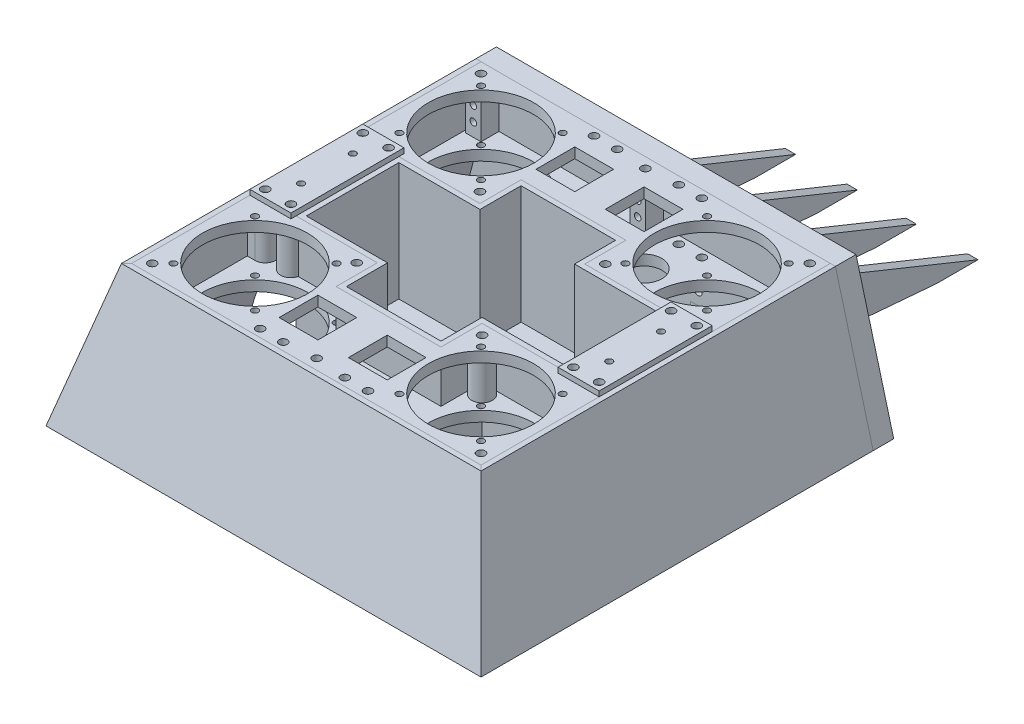
from build123d import *

# Parameters (mm, degrees)
SKETCH3_W               = 107.95
SKETCH3_H               = 76.2
SKETCH3_R               = 32.5
BOSS_EXTRUDE1_DEPTH     = 6.35
SKETCH12_W              = 25.4
SKETCH12_H              = 6.35
BOSS_EXTRUDE8_DEPTH     = 6.35
SKETCH5_R               = 10.9728
CUT_EXTRUDE1_DEPTH      = 156.930970304
SKETCH47_W              = 24
SKETCH47_H              = 24
CUT_EXTRUDE19_DEPTH     = 6.35
SKETCH22_R              = 2.0193
CUT_EXTRUDE7_DEPTH      = 158.346798506
SKETCH33_R              = 2.5527
CUT_EXTRUDE10_DEPTH     = 158.346798506
SKETCH18_R              = 2.5527
CUT_EXTRUDE5_DEPTH      = 158.346798506
CUT_EXTRUDE5_DEPTH_BACK = 158.346798506
SKETCH19_W              = 64.782960534
SKETCH19_H              = 25.4
CUT_EXTRUDE6_DEPTH      = 158.346798506
CUT_EXTRUDE6_DEPTH_BACK = 158.346798506
CIRPATTERN2_COUNT       = 2
SKETCH13_W              = 25.4
SKETCH13_H              = 69.85
BOSS_EXTRUDE9_DEPTH     = 3.175
SKETCH14_R              = 2
CUT_EXTRUDE2_DEPTH      = 3.175
SKETCH16_R              = 2.5527
CUT_EXTRUDE4_DEPTH      = 180.941566904
CUT_EXTRUDE4_DEPTH_BACK = 180.941566904
BOSS_EXTRUDE10_DEPTH    = 73.025
BOSS_EXTRUDE11_DEPTH    = 9.525
SKETCH26_R              = 6.35
BOSS_EXTRUDE12_DEPTH    = 25.4
SKETCH27_R              = 4.7625
CUT_EXTRUDE8_DEPTH      = 171.6248663
BOSS_EXTRUDE5_DEPTH     = 12.7
BOSS_EXTRUDE13_DEPTH    = 25.4
SKETCH29_R              = 4.7625
CUT_EXTRUDE9_DEPTH      = 210.078448268
SKETCH34_W              = 9.525
SKETCH34_H              = 11.1125
BOSS_EXTRUDE14_DEPTH    = 25.4
SKETCH36_R              = 2.0193
CUT_EXTRUDE11_DEPTH     = 207.517029638
LPATTERN1_COUNT         = 3
LPATTERN1_PITCH         = 101.6
SKETCH37_R              = 2.5527
CUT_EXTRUDE12_DEPTH     = 304.667377102
SKETCH38_R              = 2.0193
CUT_EXTRUDE13_DEPTH     = 294.080195203
SKETCH39_R              = 4.7625
BOSS_EXTRUDE15_DEPTH    = 4.7625
LPATTERN2_COUNT         = 2
LPATTERN2_PITCH         = 38.1
SKETCH40_R              = 2.5527
SKETCH40_W              = 9.525
SKETCH40_H              = 9.525
CUT_EXTRUDE14_DEPTH     = 294.080195203
SKETCH41_R              = 2.0193
CUT_EXTRUDE15_DEPTH     = 304.667377102
SKETCH43_R              = 18
CUT_EXTRUDE17_DEPTH     = 44.45
CUT_EXTRUDE16_START     = -82.55
CUT_EXTRUDE16_DEPTH     = 137.363629721
SKETCH44_R              = 14
CUT_EXTRUDE18_DEPTH     = 38.1
BOSS_EXTRUDE16_START    = 12.7
SKETCH45_R              = 4.7625
BOSS_EXTRUDE16_DEPTH    = 163.5125
SKETCH46_R              = 5.3975
BOSS_EXTRUDE17_DEPTH    = 6.35
LPATTERN3_COUNT         = 2
LPATTERN3_PITCH         = 38.1


with BuildPart() as part:
    # Sketch3 → Boss-Extrude1 (new body)
    with BuildSketch(Plane(origin=(0, 53.975, 0), x_dir=(1, 0, 0), z_dir=(0, 1, 0))):
        with Locations((-53.975, 69.85)):
            Rectangle(SKETCH3_W, SKETCH3_H)
        with Locations(Location((-69.85, 69.85, 0), (0, 0, 270))):
            Circle(SKETCH3_R, mode=Mode.SUBTRACT)
    extrude(amount=BOSS_EXTRUDE1_DEPTH)

    # Sketch12 → Boss-Extrude8 (add)
    with BuildSketch(Plane(origin=(0, 60.325, 0), x_dir=(1, 0, 0), z_dir=(0, 1, 0))):
        with Locations((-95.25, 28.575)):
            Rectangle(SKETCH12_W, SKETCH12_H)
    extrude(amount=-BOSS_EXTRUDE8_DEPTH)


with BuildPart() as body_2:
    # Mirror1: mirrored copy
    add(part.part.mirror(Plane.ZX.offset(73.025)))

    # Mirror2 2: body 2 across plane


with BuildPart() as part_1:
    add(part.part)

    # Mirror2: part across plane
    add(part.part.mirror(Plane(origin=(0, 0, 0), x_dir=(0, 0, 1), z_dir=(1, 0, 0))))

    # Sketch5 → Cut-Extrude1 (cut, through all)
    with BuildSketch(Plane(origin=(0, 60.325, 0), x_dir=(1, 0, 0), z_dir=(0, 1, 0))):
        with Locations(Location((-21.415333079, 79.375, 0), (0, 0, 270))):
            Circle(SKETCH5_R)
    cut_extrude1 = extrude(amount=-CUT_EXTRUDE1_DEPTH, mode=Mode.SUBTRACT)


with BuildPart() as body_2_1:
    add(body_2.part)
    add(body_2.part.mirror(Plane(origin=(0, 0, 0), x_dir=(0, 0, 1), z_dir=(1, 0, 0))))

    # Sketch47 → Cut-Extrude19 (cut)
    with BuildSketch(Plane(origin=(0, 92.075, 0), x_dir=(1, 0, 0), z_dir=(0, 1, 0))):
        with Locations((-21.415333079, 79.375)):
            Rectangle(SKETCH47_W, SKETCH47_H)
    cut_extrude19 = extrude(amount=-CUT_EXTRUDE19_DEPTH, mode=Mode.SUBTRACT)


with BuildPart() as cut_extrude7_tool:
    # Sketch22 → Cut-Extrude7 (new, through all)
    with BuildSketch(Plane(origin=(0, 92.075, 0), x_dir=(1, 0, 0), z_dir=(0, 1, 0))):
        with Locations(Location((-95.076034419, 95.076034419, 0), (0, 0, 270))):
            Circle(SKETCH22_R)
        with Locations(Location((-44.623965581, 95.076034419, 0), (0, 0, 270))):
            Circle(SKETCH22_R)
        with Locations(Location((-44.623965581, 44.623965581, 0), (0, 0, 270))):
            Circle(SKETCH22_R)
        with Locations(Location((-95.076034419, 44.623965581, 0), (0, 0, 270))):
            Circle(SKETCH22_R)
    cut_extrude7 = extrude(amount=-CUT_EXTRUDE7_DEPTH)


with BuildPart() as part_2:
    add(part_1.part)

    # Cut-Extrude7: cut by cut_extrude7_tool
    add(cut_extrude7_tool.part, mode=Mode.SUBTRACT)


with BuildPart() as body_2_2:
    add(body_2_1.part)

    # Cut-Extrude7: cut by cut_extrude7_tool
    add(cut_extrude7_tool.part, mode=Mode.SUBTRACT)


with BuildPart() as cut_extrude10_tool:
    # Sketch33 → Cut-Extrude10 (new, through all)
    with BuildSketch(Plane.XZ.offset(-53.975)):
        with Locations(Location((-19.05, -103.1875, 0), (0, 0, 270))):
            Circle(SKETCH33_R)
        with Locations(Location((-33.3375, -103.1875, 0), (0, 0, 270))):
            Circle(SKETCH33_R)
    cut_extrude10 = extrude(amount=-CUT_EXTRUDE10_DEPTH)


with BuildPart() as part_3:
    add(part_2.part)

    # Cut-Extrude10: cut by cut_extrude10_tool
    add(cut_extrude10_tool.part, mode=Mode.SUBTRACT)


with BuildPart() as body_2_3:
    add(body_2_2.part)

    # Cut-Extrude10: cut by cut_extrude10_tool
    add(cut_extrude10_tool.part, mode=Mode.SUBTRACT)


with BuildPart() as mirror8_tool:
    # Mirror8: Cut-Extrude1, Cut-Extrude19, Cut-Extrude7, Cut-Extrude10 across plane
    add(cut_extrude1.mirror(Plane(origin=(0, 0, 0), x_dir=(0, 0, 1), z_dir=(1, 0, 0))))
    add(cut_extrude19.mirror(Plane(origin=(0, 0, 0), x_dir=(0, 0, 1), z_dir=(1, 0, 0))))
    add(cut_extrude7.mirror(Plane(origin=(0, 0, 0), x_dir=(0, 0, 1), z_dir=(1, 0, 0))))
    add(cut_extrude10.mirror(Plane(origin=(0, 0, 0), x_dir=(0, 0, 1), z_dir=(1, 0, 0))))


with BuildPart() as part_4:
    add(part_3.part)

    # Mirror8: cut by mirror8_tool
    add(mirror8_tool.part, mode=Mode.SUBTRACT)


with BuildPart() as body_2_4:
    add(body_2_3.part)

    # Mirror8: cut by mirror8_tool
    add(mirror8_tool.part, mode=Mode.SUBTRACT)


with BuildPart() as cut_extrude5_tool:
    # Sketch18 → Cut-Extrude5 (new, two sides)
    with BuildSketch(Plane(origin=(0, 92.075, 0), x_dir=(1, 0, 0), z_dir=(0, 1, 0))) as cut_extrude5_sk:
        with Locations(Location((-101.6, 101.6, 0), (0, 0, 90))):
            Circle(SKETCH18_R)
        with Locations(Location((0, 101.6, 0), (0, 0, 90))):
            Circle(SKETCH18_R)
        with Locations(Location((101.6, 101.6, 0), (0, 0, 90))):
            Circle(SKETCH18_R)
        with Locations(Location((38.741480267, 38.1, 0), (0, 0, 90))):
            Circle(SKETCH18_R)
        with Locations(Location((-38.741480267, 38.1, 0), (0, 0, 90))):
            Circle(SKETCH18_R)
    extrude(amount=CUT_EXTRUDE5_DEPTH)
    extrude(cut_extrude5_sk.sketch, amount=-CUT_EXTRUDE5_DEPTH_BACK)


with BuildPart() as part_5:
    add(part_4.part)

    # Cut-Extrude5: cut by cut_extrude5_tool
    add(cut_extrude5_tool.part, mode=Mode.SUBTRACT)


with BuildPart() as body_2_5:
    add(body_2_4.part)

    # Cut-Extrude5: cut by cut_extrude5_tool
    add(cut_extrude5_tool.part, mode=Mode.SUBTRACT)


with BuildPart() as cut_extrude6_tool:
    # Sketch19 → Cut-Extrude6 (new, two sides)
    with BuildSketch(Plane(origin=(0, 92.075, 0), x_dir=(1, 0, 0), z_dir=(0, 1, 0))) as cut_extrude6_sk:
        with Locations((0, 44.45)):
            Rectangle(SKETCH19_W, SKETCH19_H)
    extrude(amount=CUT_EXTRUDE6_DEPTH)
    extrude(cut_extrude6_sk.sketch, amount=-CUT_EXTRUDE6_DEPTH_BACK)


with BuildPart() as part_6:
    add(part_5.part)

    # Cut-Extrude6: cut by cut_extrude6_tool
    add(cut_extrude6_tool.part, mode=Mode.SUBTRACT)


with BuildPart() as body_2_6:
    add(body_2_5.part)

    # Cut-Extrude6: cut by cut_extrude6_tool
    add(cut_extrude6_tool.part, mode=Mode.SUBTRACT)


with BuildPart() as cirpattern2_1:
    # CirPattern2: pattern copy
    add(body_2_6.part.rotate(Axis((0, 0, 0), (0, 1, 0)), 1 * 360 / CIRPATTERN2_COUNT))


with BuildPart() as cirpattern2_2:
    # CirPattern2: pattern copy
    add(part_6.part.rotate(Axis((0, 0, 0), (0, 1, 0)), 1 * 360 / CIRPATTERN2_COUNT))


with BuildPart() as body_5:
    # Sketch13 → Boss-Extrude9 (new body)
    with BuildSketch(Plane(origin=(0, 92.075, 0), x_dir=(1, 0, 0), z_dir=(0, 1, 0))):
        with Locations((-95.25, 0)):
            Rectangle(SKETCH13_W, SKETCH13_H)
    extrude(amount=BOSS_EXTRUDE9_DEPTH)

    # Sketch14 → Cut-Extrude2 (cut)
    with BuildSketch(Plane(origin=(0, 95.25, 0), x_dir=(1, 0, 0), z_dir=(0, 1, 0))):
        with Locations(Location((-95.25, 16, 0), (0, 0, 270))):
            Circle(SKETCH14_R)
        with Locations(Location((-95.25, -16, 0), (0, 0, 270))):
            Circle(SKETCH14_R)
    extrude(amount=-CUT_EXTRUDE2_DEPTH, mode=Mode.SUBTRACT)


with BuildPart() as body_6:
    # Mirror11: mirrored copy
    add(body_5.part.mirror(Plane.ZX.offset(73.025)))


with BuildPart() as body_7:
    # Mirror12: mirrored copy
    add(body_6.part.mirror(Plane(origin=(0, 0, 0), x_dir=(0, 0, 1), z_dir=(1, 0, 0))))


with BuildPart() as body_8:
    # Mirror12 2: mirrored copy
    add(body_5.part.mirror(Plane(origin=(0, 0, 0), x_dir=(0, 0, 1), z_dir=(1, 0, 0))))


with BuildPart() as cut_extrude4_tool:
    # Sketch16 → Cut-Extrude4 (new, two sides)
    with BuildSketch(Plane(origin=(0, 0, 0), x_dir=(1, 0, 0), z_dir=(0, 1, 0))) as cut_extrude4_sk:
        with Locations(Location((-103.1875, 30.1625, 0), (0, 0, 90))):
            Circle(SKETCH16_R)
        with Locations(Location((-87.3125, 30.1625, 0), (0, 0, 90))):
            Circle(SKETCH16_R)
        with Locations(Location((87.3125, 30.1625, 0), (0, 0, 90))):
            Circle(SKETCH16_R)
        with Locations(Location((103.1875, 30.1625, 0), (0, 0, 90))):
            Circle(SKETCH16_R)
        with Locations(Location((103.1875, -30.1625, 0), (0, 0, 90))):
            Circle(SKETCH16_R)
        with Locations(Location((87.3125, -30.1625, 0), (0, 0, 90))):
            Circle(SKETCH16_R)
        with Locations(Location((-87.3125, -30.1625, 0), (0, 0, 90))):
            Circle(SKETCH16_R)
        with Locations(Location((-103.1875, -30.1625, 0), (0, 0, 90))):
            Circle(SKETCH16_R)
    extrude(amount=CUT_EXTRUDE4_DEPTH)
    extrude(cut_extrude4_sk.sketch, amount=-CUT_EXTRUDE4_DEPTH_BACK)


with BuildPart() as part_7:
    add(part_6.part)

    # Cut-Extrude4: cut by cut_extrude4_tool
    add(cut_extrude4_tool.part, mode=Mode.SUBTRACT)


with BuildPart() as body_2_7:
    add(body_2_6.part)

    # Cut-Extrude4: cut by cut_extrude4_tool
    add(cut_extrude4_tool.part, mode=Mode.SUBTRACT)


with BuildPart() as cirpattern2_1_1:
    add(cirpattern2_1.part)

    # Cut-Extrude4: cut by cut_extrude4_tool
    add(cut_extrude4_tool.part, mode=Mode.SUBTRACT)


with BuildPart() as cirpattern2_2_1:
    add(cirpattern2_2.part)

    # Cut-Extrude4: cut by cut_extrude4_tool
    add(cut_extrude4_tool.part, mode=Mode.SUBTRACT)


with BuildPart() as body_5_1:
    add(body_5.part)

    # Cut-Extrude4: cut by cut_extrude4_tool
    add(cut_extrude4_tool.part, mode=Mode.SUBTRACT)


with BuildPart() as body_6_1:
    add(body_6.part)

    # Cut-Extrude4: cut by cut_extrude4_tool
    add(cut_extrude4_tool.part, mode=Mode.SUBTRACT)


with BuildPart() as body_7_1:
    add(body_7.part)

    # Cut-Extrude4: cut by cut_extrude4_tool
    add(cut_extrude4_tool.part, mode=Mode.SUBTRACT)


with BuildPart() as body_8_1:
    add(body_8.part)

    # Cut-Extrude4: cut by cut_extrude4_tool
    add(cut_extrude4_tool.part, mode=Mode.SUBTRACT)


with BuildPart() as body_9:
    # Sketch20 → Boss-Extrude10 (new body)
    with BuildSketch(Plane(origin=(0, 92.075, 0), x_dir=(1, 0, 0), z_dir=(0, 1, 0))):
        Polygon((-82.55, -31.75), (-32.391480267, -31.75), (-32.391480267, -57.15), (32.391480267, -57.15), (32.391480267, -31.75), (82.55, -31.75), (82.55, 31.75), (32.391480267, 31.75), (32.391480267, 57.15), (-32.391480267, 57.15), (-32.391480267, 31.75), (-82.55, 31.75), align=None)
        Polygon((-79.375, 28.575), (-79.375, -28.575), (-29.216480267, -28.575), (-29.216480267, -53.975), (29.216480267, -53.975), (29.216480267, -28.575), (79.375, -28.575), (79.375, 28.575), (29.216480267, 28.575), (29.216480267, 53.975), (-29.216480267, 53.975), (-29.216480267, 28.575), align=None, mode=Mode.SUBTRACT)
    extrude(amount=-BOSS_EXTRUDE10_DEPTH)

    # Sketch23 → Boss-Extrude11 (add)
    with BuildSketch(Plane.XZ.offset(-19.05)):
        Polygon((-82.55, 31.75), (-82.55, -31.75), (-32.391480267, -31.75), (-32.391480267, -57.15), (32.391480267, -57.15), (32.391480267, -31.75), (82.55, -31.75), (82.55, 31.75), (32.391480267, 31.75), (32.391480267, 57.15), (-32.391480267, 57.15), (-32.391480267, 31.75), align=None)
    extrude(amount=BOSS_EXTRUDE11_DEPTH)

    # Sketch26 → Boss-Extrude12 (add)
    with BuildSketch(Plane(origin=(0, 60.325, 0), x_dir=(1, 0, 0), z_dir=(0, 1, 0))):
        with Locations((-87.3125, 30.1625)):
            Circle(SKETCH26_R)
        with Locations((-87.3125, -30.1625)):
            Circle(SKETCH26_R)
        with Locations((87.3125, 30.1625)):
            Circle(SKETCH26_R)
        with Locations((87.3125, -30.1625)):
            Circle(SKETCH26_R)
        with BuildLine():
            Line((-38.741480267, -31.75), (-32.391480267, -31.75))
            Line((-32.391480267, -31.75), (-32.391480267, -38.1))
            ThreePointArc((-32.391480267, -38.1), (-43.231608327, -42.590128061), (-38.741480267, -31.75))
        make_face()
        with BuildLine():
            Line((32.391480267, -38.1), (32.391480267, -31.75))
            Line((32.391480267, -31.75), (38.741480267, -31.75))
            ThreePointArc((38.741480267, -31.75), (43.231608327, -42.590128061), (32.391480267, -38.1))
        make_face()
        with BuildLine():
            Line((38.741480267, 31.75), (32.391480267, 31.75))
            Line((32.391480267, 31.75), (32.391480267, 38.1))
            ThreePointArc((32.391480267, 38.1), (43.231608327, 42.590128061), (38.741480267, 31.75))
        make_face()
        with BuildLine():
            Line((-32.391480267, 38.1), (-32.391480267, 31.75))
            Line((-32.391480267, 31.75), (-38.741480267, 31.75))
            ThreePointArc((-38.741480267, 31.75), (-43.231608327, 42.590128061), (-32.391480267, 38.1))
        make_face()
    extrude(amount=BOSS_EXTRUDE12_DEPTH)

    # Sketch27 → Cut-Extrude8 (cut, through all)
    with BuildSketch(Plane.XZ.offset(-85.725)):
        with Locations((-87.3125, 30.1625)):
            Circle(SKETCH27_R)
        with Locations(Location((-38.741480267, 38.1, 0), (0, 0, 90))):
            Circle(SKETCH27_R)
        with Locations(Location((38.741480267, 38.1, 0), (0, 0, 90))):
            Circle(SKETCH27_R)
        with Locations(Location((87.3125, 30.1625, 0), (0, 0, 180))):
            Circle(SKETCH27_R)
        with Locations(Location((87.3125, -30.1625, 0), (0, 0, 180))):
            Circle(SKETCH27_R)
        with Locations(Location((38.741480267, -38.1, 0), (0, 0, 90))):
            Circle(SKETCH27_R)
        with Locations(Location((-38.741480267, -38.1, 0), (0, 0, 90))):
            Circle(SKETCH27_R)
        with Locations((-87.3125, -30.1625)):
            Circle(SKETCH27_R)
    extrude(amount=CUT_EXTRUDE8_DEPTH, mode=Mode.SUBTRACT)

    # Sketch43 → Cut-Extrude17 (cut)
    with BuildSketch(Plane.ZY.offset(82.55)):
        with Locations((0, 26.797)):
            Circle(SKETCH43_R)
    extrude(amount=-CUT_EXTRUDE17_DEPTH, mode=Mode.SUBTRACT)

    # Sketch44 → Cut-Extrude18 (cut)
    with BuildSketch(Plane.ZY.offset(38.1)):
        with Locations((0, 26.797)):
            Circle(SKETCH44_R)
    extrude(amount=-CUT_EXTRUDE18_DEPTH, mode=Mode.SUBTRACT)


with BuildPart() as body_10:
    # Sketch9 → Boss-Extrude5 (new body)
    with BuildSketch(Plane(origin=(0, 0, -107.95), x_dir=(-1, 0, 0), z_dir=(0, 0, -1))):
        Polygon((-111.125, 92.075), (-134.435239996, 5.08), (134.435239996, 5.08), (111.125, 92.075), align=None)
    extrude(amount=BOSS_EXTRUDE5_DEPTH)

    # Sketch37 → Cut-Extrude12 (cut, through all)
    with BuildSketch(Plane(origin=(0, 0, -120.65), x_dir=(-1, 0, 0), z_dir=(0, 0, -1))):
        with Locations((0, 77.47)):
            Circle(SKETCH37_R)
        with Locations((0, 68.58)):
            Circle(SKETCH37_R)
        with Locations((26.19375, 49.2125)):
            Circle(SKETCH37_R)
        with Locations((40.48125, 49.2125)):
            Circle(SKETCH37_R)
        with Locations((101.6, 68.58)):
            Circle(SKETCH37_R)
        with Locations((101.6, 77.47)):
            Circle(SKETCH37_R)
        with Locations((116.150302781, 48.34568404)):
            Circle(SKETCH37_R)
        with Locations((121.08080559, 29.944797049)):
            Circle(SKETCH37_R)
        with Locations((126.0113084, 11.543910058)):
            Circle(SKETCH37_R)
        with Locations((-126.0113084, 11.543910058)):
            Circle(SKETCH37_R)
        with Locations((-121.08080559, 29.944797049)):
            Circle(SKETCH37_R)
        with Locations((-116.150302781, 48.34568404)):
            Circle(SKETCH37_R)
        with Locations((-101.6, 77.47)):
            Circle(SKETCH37_R)
        with Locations((-101.6, 68.58)):
            Circle(SKETCH37_R)
        with Locations((-40.48125, 49.2125)):
            Circle(SKETCH37_R)
        with Locations((-26.19375, 49.2125)):
            Circle(SKETCH37_R)
    extrude(amount=-CUT_EXTRUDE12_DEPTH, mode=Mode.SUBTRACT)

    # Sketch40 → Cut-Extrude14 (cut, through all)
    with BuildSketch(Plane.XY.offset(-107.95)):
        with Locations((-26.19375, 49.249051354)):
            Circle(SKETCH40_R)
        with Locations((-26.19375, 36.549051354)):
            Circle(SKETCH40_R)
        with Locations((-26.19375, 11.149051354)):
            Circle(SKETCH40_R)
        with Locations((-64.29375, 49.249051354)):
            Circle(SKETCH40_R)
        with Locations((-64.29375, 36.549051354)):
            Circle(SKETCH40_R)
        with Locations((-64.29375, 11.149051354)):
            Circle(SKETCH40_R)
        with Locations(Location((64.29375, 11.149051354, 0), (0, 0, 180))):
            Circle(SKETCH40_R)
        with Locations(Location((26.19375, 11.149051354, 0), (0, 0, 180))):
            Circle(SKETCH40_R)
        with Locations(Location((26.19375, 36.549051354, 0), (0, 0, 180))):
            Circle(SKETCH40_R)
        with Locations(Location((64.29375, 36.549051354, 0), (0, 0, 180))):
            Circle(SKETCH40_R)
        with Locations(Location((64.29375, 49.249051354, 0), (0, 0, 180))):
            Circle(SKETCH40_R)
        with Locations((26.19375, 49.249051354)):
            Circle(SKETCH40_R)
        with Locations((64.29375, 23.849051354)):
            Rectangle(SKETCH40_W, SKETCH40_H)
        with Locations((26.19375, 23.849051354)):
            Rectangle(SKETCH40_W, SKETCH40_H)
        with Locations((-26.19375, 23.849051354)):
            Rectangle(SKETCH40_W, SKETCH40_H)
        with Locations((-64.29375, 23.849051354)):
            Rectangle(SKETCH40_W, SKETCH40_H)
    extrude(amount=-CUT_EXTRUDE14_DEPTH, mode=Mode.SUBTRACT)


with BuildPart() as body_11:
    # Sweep2: sweep along a path in Sketch25
    with BuildLine(Plane(origin=(0, 92.075, 0), x_dir=(1, 0, 0), z_dir=(0, 1, 0))) as sweep2_path:
        Line((-107.95, 107.95), (-107.95, -107.95))
        Line((-107.95, -107.95), (107.95, -107.95))
        Line((107.95, -107.95), (107.95, 107.95))
    # Sketch24 → Sweep2 (sweep)
    with BuildSketch(Plane.XY.offset(-107.95)):
        Polygon((-134.435239996, 5.08), (-111.125, 92.075), (-107.95, 92.075), (-107.95, 53.975), (-121.051375764, 5.08), align=None)
    sweep(path=sweep2_path.line, transition=Transition.RIGHT)

    # Sketch28 → Boss-Extrude13 (add)
    with BuildSketch(Plane(origin=(0, 60.325, 0), x_dir=(1, 0, 0), z_dir=(0, 1, 0))):
        with BuildLine():
            Line((-103.1875, 36.5125), (-107.95, 36.5125))
            Line((-107.95, 36.5125), (-107.95, 23.8125))
            Line((-107.95, 23.8125), (-103.1875, 23.8125))
            ThreePointArc((-103.1875, 23.8125), (-96.8375, 30.1625), (-103.1875, 36.5125))
        make_face()
        with BuildLine():
            Line((-103.1875, -36.5125), (-107.95, -36.5125))
            Line((-107.95, -36.5125), (-107.95, -23.8125))
            Line((-107.95, -23.8125), (-103.1875, -23.8125))
            ThreePointArc((-103.1875, -23.8125), (-96.8375, -30.1625), (-103.1875, -36.5125))
        make_face()
        with BuildLine():
            Line((-101.6, -95.25), (-107.95, -95.25))
            Line((-107.95, -95.25), (-107.95, -107.95))
            Line((-107.95, -107.95), (-95.25, -107.95))
            Line((-95.25, -107.95), (-95.25, -101.6))
            ThreePointArc((-95.25, -101.6), (-97.109871939, -97.109871939), (-101.6, -95.25))
        make_face()
        with BuildLine():
            Line((6.35, -101.6), (6.35, -107.95))
            Line((6.35, -107.95), (-6.35, -107.95))
            Line((-6.35, -107.95), (-6.35, -101.6))
            ThreePointArc((-6.35, -101.6), (0, -95.25), (6.35, -101.6))
        make_face()
        with BuildLine():
            Line((107.95, 23.8125), (103.1875, 23.8125))
            ThreePointArc((103.1875, 23.8125), (96.8375, 30.1625), (103.1875, 36.5125))
            Line((103.1875, 36.5125), (107.95, 36.5125))
            Line((107.95, 36.5125), (107.95, 23.8125))
        make_face()
        with BuildLine():
            Line((103.1875, -36.5125), (107.95, -36.5125))
            Line((107.95, -36.5125), (107.95, -23.8125))
            Line((107.95, -23.8125), (103.1875, -23.8125))
            ThreePointArc((103.1875, -23.8125), (96.8375, -30.1625), (103.1875, -36.5125))
        make_face()
        with BuildLine():
            Line((95.25, -107.95), (95.25, -101.6))
            ThreePointArc((95.25, -101.6), (97.109871939, -97.109871939), (101.6, -95.25))
            Line((101.6, -95.25), (107.95, -95.25))
            Line((107.95, -95.25), (107.95, -107.95))
            Line((107.95, -107.95), (95.25, -107.95))
        make_face()
    extrude(amount=BOSS_EXTRUDE13_DEPTH)

    # Sketch29 → Cut-Extrude9 (cut, through all)
    with BuildSketch(Plane(origin=(0, 92.075, 0), x_dir=(1, 0, 0), z_dir=(0, 1, 0))):
        with Locations(Location((-103.1875, 30.1625, 0), (0, 0, 180))):
            Circle(SKETCH29_R)
        with Locations(Location((-103.1875, -30.1625, 0), (0, 0, 180))):
            Circle(SKETCH29_R)
        with Locations(Location((-101.6, -101.6, 0), (0, 0, 270))):
            Circle(SKETCH29_R)
        with Locations(Location((0, -101.6, 0), (0, 0, 270))):
            Circle(SKETCH29_R)
        with Locations(Location((101.6, -101.6, 0), (0, 0, 90))):
            Circle(SKETCH29_R)
        with Locations((103.1875, -30.1625)):
            Circle(SKETCH29_R)
        with Locations((103.1875, 30.1625)):
            Circle(SKETCH29_R)
    extrude(amount=-CUT_EXTRUDE9_DEPTH, mode=Mode.SUBTRACT)

    # Sketch42 → Cut-Extrude16 (cut, through all)
    with BuildSketch(Plane(origin=(0, 0, 0), x_dir=(0, 0, -1), z_dir=(1, 0, 0)).offset(CUT_EXTRUDE16_START)):
        with BuildLine():
            Line((-25.4, 5.08), (25.4, 5.08))
            Line((25.4, 5.08), (25.4, 26.797))
            ThreePointArc((25.4, 26.797), (0, 52.197), (-25.4, 26.797))
            Line((-25.4, 26.797), (-25.4, 5.08))
        make_face()
    extrude(amount=-CUT_EXTRUDE16_DEPTH, mode=Mode.SUBTRACT)


with BuildPart() as body_12:
    # Sketch34 → Boss-Extrude14 (new body)
    with BuildSketch(Plane(origin=(0, 60.325, 0), x_dir=(1, 0, 0), z_dir=(0, 1, 0))):
        with Locations((-101.6, 102.39375)):
            Rectangle(SKETCH34_W, SKETCH34_H)
    extrude(amount=BOSS_EXTRUDE14_DEPTH)

    # Sketch36 → Cut-Extrude11 (cut, through all)
    with BuildSketch(Plane(origin=(0, 85.725, 0), x_dir=(1, 0, 0), z_dir=(0, 1, 0))):
        with Locations(Location((-101.6, 101.6, 0), (0, 0, 270))):
            Circle(SKETCH36_R)
    extrude(amount=-CUT_EXTRUDE11_DEPTH, mode=Mode.SUBTRACT)


with BuildPart() as lpattern1_1:
    # LPattern1: pattern copy
    add(body_12.part.moved(Location(Vector(1, 0, 0) * (1 * LPATTERN1_PITCH))))


with BuildPart() as lpattern1_2:
    # LPattern1: pattern copy
    add(body_12.part.moved(Location(Vector(1, 0, 0) * (2 * LPATTERN1_PITCH))))


with BuildPart() as cut_extrude13_tool:
    # Sketch38 → Cut-Extrude13 (new, through all)
    with BuildSketch(Plane(origin=(0, 0, -107.95), x_dir=(-1, 0, 0), z_dir=(0, 0, -1))):
        with Locations((-101.6, 77.47)):
            Circle(SKETCH38_R)
        with Locations((-101.6, 68.58)):
            Circle(SKETCH38_R)
        with Locations((0, 68.58)):
            Circle(SKETCH38_R)
        with Locations((0, 77.47)):
            Circle(SKETCH38_R)
        with Locations((101.6, 68.58)):
            Circle(SKETCH38_R)
        with Locations((101.6, 77.47)):
            Circle(SKETCH38_R)
    extrude(amount=-CUT_EXTRUDE13_DEPTH)


with BuildPart() as body_12_1:
    add(body_12.part)

    # Cut-Extrude13: cut by cut_extrude13_tool
    add(cut_extrude13_tool.part, mode=Mode.SUBTRACT)


with BuildPart() as lpattern1_1_1:
    add(lpattern1_1.part)

    # Cut-Extrude13: cut by cut_extrude13_tool
    add(cut_extrude13_tool.part, mode=Mode.SUBTRACT)


with BuildPart() as lpattern1_2_1:
    add(lpattern1_2.part)

    # Cut-Extrude13: cut by cut_extrude13_tool
    add(cut_extrude13_tool.part, mode=Mode.SUBTRACT)


with BuildPart() as body_15:
    # Sketch39 → Boss-Extrude15 (new, symmetric)
    with BuildSketch(Plane.ZY.offset(26.19375)):
        with BuildLine():
            Line((-120.65, 5.08), (-130.175, 5.08))
            Line((-130.175, 5.08), (-141.187417559, 16.706597074))
            ThreePointArc((-141.187417559, 16.706597074), (-144.141343422, 23.849051354), (-141.56306962, 31.135534413))
            Line((-141.56306962, 31.135534413), (-130.175, 44.486551354))
            Line((-130.175, 44.486551354), (-130.175, 54.011551354))
            Line((-130.175, 54.011551354), (-120.65, 54.011551354))
            Line((-120.65, 54.011551354), (-120.65, 28.611551354))
            Line((-120.65, 28.611551354), (-107.95, 28.611551354))
            Line((-107.95, 28.611551354), (-107.95, 19.086551354))
            Line((-107.95, 19.086551354), (-120.65, 19.086551354))
            Line((-120.65, 19.086551354), (-120.65, 5.08))
        make_face()
        with Locations(Location((-133.35, 24.13, 0), (0, 0, 180))):
            Circle(SKETCH39_R, mode=Mode.SUBTRACT)
    extrude(amount=BOSS_EXTRUDE15_DEPTH, both=True)


with BuildPart() as lpattern2_1:
    # LPattern2: pattern copy
    add(body_15.part.moved(Location(Vector(-1, 0, 0) * (1 * LPATTERN2_PITCH))))


with BuildPart() as body_17:
    # Mirror13: mirrored copy
    add(body_15.part.mirror(Plane(origin=(0, 0, 0), x_dir=(0, 0, 1), z_dir=(1, 0, 0))))


with BuildPart() as body_18:
    # Mirror13 2: mirrored copy
    add(lpattern2_1.part.mirror(Plane(origin=(0, 0, 0), x_dir=(0, 0, 1), z_dir=(1, 0, 0))))


with BuildPart() as cut_extrude15_tool:
    # Sketch41 → Cut-Extrude15 (new, through all)
    with BuildSketch(Plane.XY.offset(-120.65)):
        with Locations((-64.29375, 49.249051354)):
            Circle(SKETCH41_R)
        with Locations((-64.29375, 36.549051354)):
            Circle(SKETCH41_R)
        with Locations((-64.29375, 11.149051354)):
            Circle(SKETCH41_R)
        with Locations((-26.19375, 11.149051354)):
            Circle(SKETCH41_R)
        with Locations((-26.19375, 36.549051354)):
            Circle(SKETCH41_R)
        with Locations((-26.19375, 49.2125)):
            Circle(SKETCH41_R)
        with Locations((26.19375, 49.2125)):
            Circle(SKETCH41_R)
        with Locations(Location((26.19375, 36.549051354, 0), (0, 0, 90))):
            Circle(SKETCH41_R)
        with Locations(Location((26.19375, 11.149051354, 0), (0, 0, 270))):
            Circle(SKETCH41_R)
        with Locations(Location((64.29375, 11.149051354, 0), (0, 0, 270))):
            Circle(SKETCH41_R)
        with Locations(Location((64.29375, 36.549051354, 0), (0, 0, 90))):
            Circle(SKETCH41_R)
        with Locations((64.29375, 49.249051354)):
            Circle(SKETCH41_R)
    extrude(amount=-CUT_EXTRUDE15_DEPTH)


with BuildPart() as body_15_1:
    add(body_15.part)

    # Cut-Extrude15: cut by cut_extrude15_tool
    add(cut_extrude15_tool.part, mode=Mode.SUBTRACT)


with BuildPart() as lpattern2_1_1:
    add(lpattern2_1.part)

    # Cut-Extrude15: cut by cut_extrude15_tool
    add(cut_extrude15_tool.part, mode=Mode.SUBTRACT)


with BuildPart() as body_17_1:
    add(body_17.part)

    # Cut-Extrude15: cut by cut_extrude15_tool
    add(cut_extrude15_tool.part, mode=Mode.SUBTRACT)


with BuildPart() as body_18_1:
    add(body_18.part)

    # Cut-Extrude15: cut by cut_extrude15_tool
    add(cut_extrude15_tool.part, mode=Mode.SUBTRACT)


with BuildPart() as body_19:
    # Sketch45 → Boss-Extrude16 (new body)
    with BuildSketch(Plane.ZY.offset(69.05625).offset(BOSS_EXTRUDE16_START)):
        with Locations((-133.35, 24.13)):
            Circle(SKETCH45_R)
    extrude(amount=-BOSS_EXTRUDE16_DEPTH)


with BuildPart() as body_20:
    # Sketch46 → Boss-Extrude17 (new body)
    with BuildSketch(Plane(origin=(-59.53125, 0, 0), x_dir=(0, 0, -1), z_dir=(1, 0, 0))):
        with BuildLine():
            Line((123.825, 8.255), (123.825, 40.005))
            Line((123.825, 40.005), (139.7, 60.325))
            ThreePointArc((139.7, 60.325), (140.02023654, 48.355510338), (148.610795915, 40.014435836))
            Line((148.610795915, 40.014435836), (247.65, 0))
            Line((247.65, 0), (222.25, 0))
            Line((222.25, 0), (123.825, 8.255))
        make_face()
        with Locations((133.35, 24.13)):
            Circle(SKETCH46_R, mode=Mode.SUBTRACT)
    boss_extrude17 = extrude(amount=BOSS_EXTRUDE17_DEPTH)


with BuildPart() as lpattern3_1:
    # LPattern3: Boss-Extrude17 ×2
    with Locations(*[(i * LPATTERN3_PITCH, 0, 0) for i in range(1, LPATTERN3_COUNT)]):
        add(boss_extrude17)


with BuildPart() as body_22:
    # Mirror14: mirrored copy
    add(lpattern3_1.part.mirror(Plane(origin=(0, 0, 0), x_dir=(0, 0, 1), z_dir=(1, 0, 0))))


with BuildPart() as body_23:
    # Mirror14 2: mirrored copy
    add(body_20.part.mirror(Plane(origin=(0, 0, 0), x_dir=(0, 0, 1), z_dir=(1, 0, 0))))


solid = Compound([part_7.part, body_2_7.part, cirpattern2_1_1.part, cirpattern2_2_1.part, body_5_1.part, body_6_1.part, body_7_1.part, body_8_1.part, body_9.part, body_10.part, body_11.part, body_12_1.part, lpattern1_1_1.part, lpattern1_2_1.part, body_15_1.part, lpattern2_1_1.part, body_17_1.part, body_18_1.part, body_19.part, body_20.part, lpattern3_1.part, body_22.part, body_23.part])
